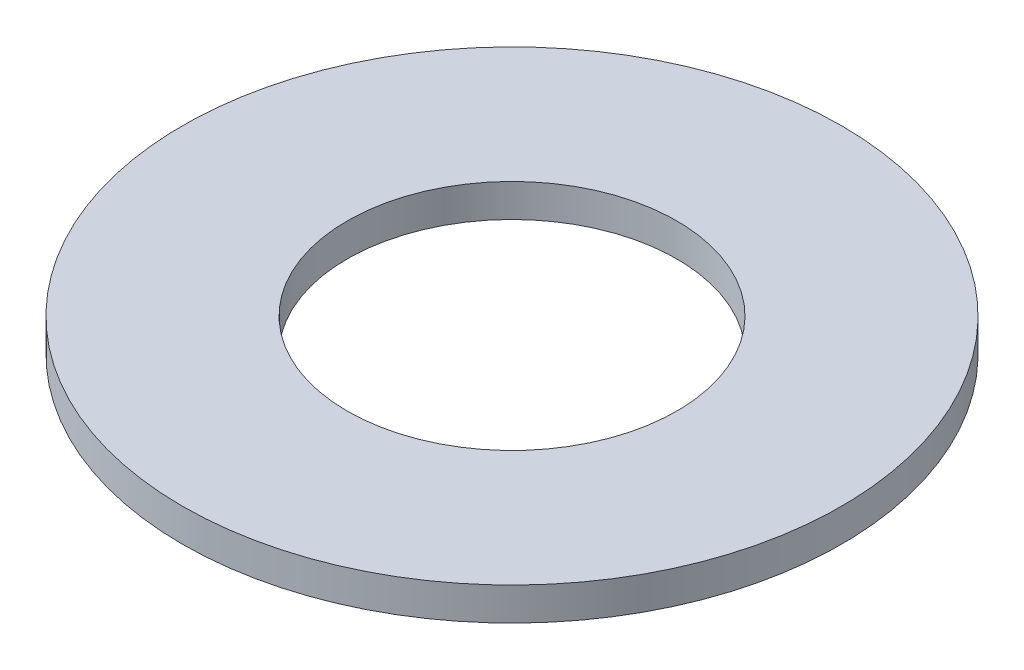
from build123d import *

# Parameters (mm, degrees)
SKETCH1_R           = 10
SKETCH1_R_2         = 5
BOSS_EXTRUDE1_DEPTH = 1


with BuildPart() as part:
    # Sketch1 → Boss-Extrude1 (new body)
    with BuildSketch(Plane(origin=(0, 0, 0), x_dir=(1, 0, 0), z_dir=(0, 1, 0))):
        Circle(SKETCH1_R)
        Circle(SKETCH1_R_2, mode=Mode.SUBTRACT)
    extrude(amount=BOSS_EXTRUDE1_DEPTH)


solid = part.part
